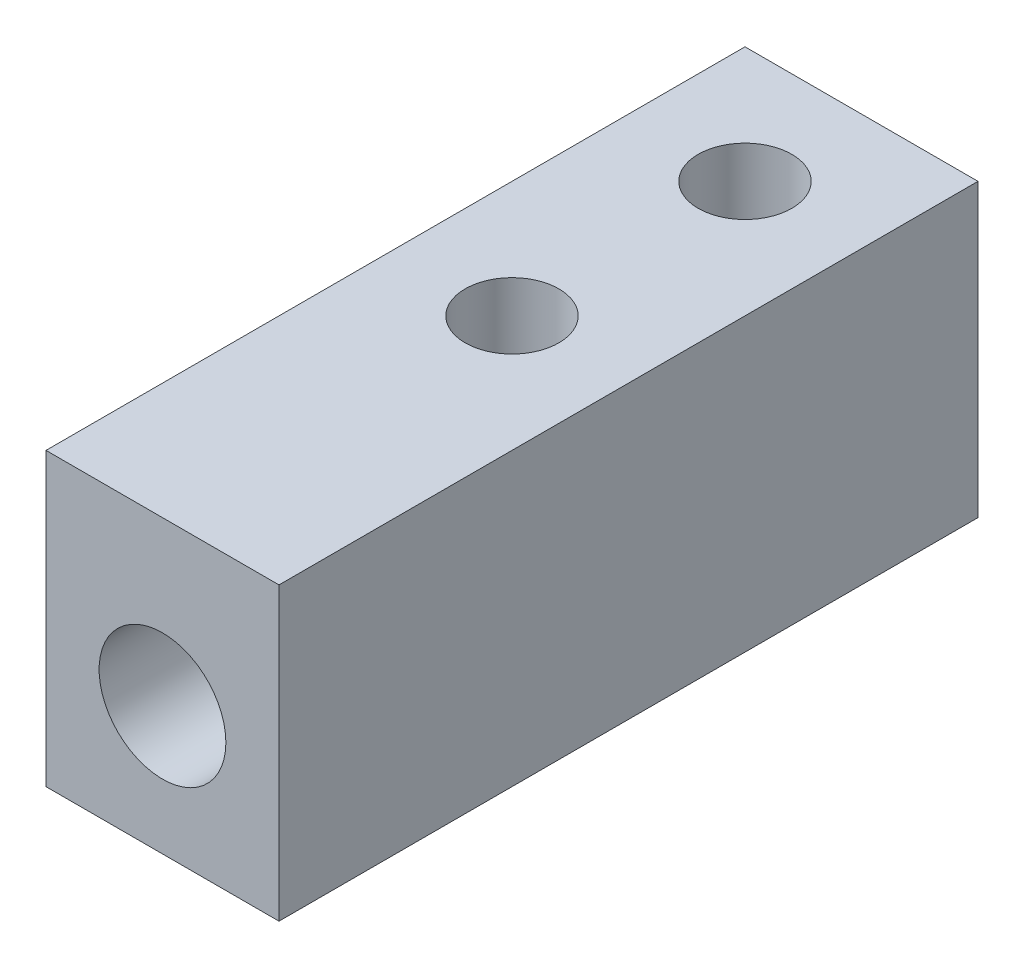
from build123d import *

# Parameters (mm, degrees)
SKETCH1_W                    = 12.7
SKETCH1_H                    = 12.7
BOSS_EXTRUDE1_DEPTH          = 15.875
F_7_0_201_DIAMETER_HOLE1_D   = 5.1054
SKETCH5_W                    = 12.7
SKETCH5_H                    = 12.7
BOSS_EXTRUDE2_DEPTH          = 6.35
F_5_16_24_TAPPED_HOLE1_D     = 6.9088
F_5_16_24_TAPPED_HOLE1_DEPTH = 19.304
F_5_16_24_TAPPED_HOLE1_TIP   = 2.075612922
BOSS_EXTRUDE4_START          = 3.175
SKETCH9_W                    = 12.7
SKETCH9_H                    = 38.1
SKETCH9_R                    = 2.5527
BOSS_EXTRUDE4_DEPTH          = 3.175


with BuildPart() as part:
    # Sketch1 → Boss-Extrude1 (new, symmetric)
    with BuildSketch(Plane.XY):
        Rectangle(SKETCH1_W, SKETCH1_H)
    extrude(amount=BOSS_EXTRUDE1_DEPTH, both=True)

    # #7 (0.201) Diameter Hole1 (through all)
    with Locations(Plane(origin=(0, 6.35, 0), x_dir=(1, 0, 0), z_dir=(0, 1, 0))):
        with Locations((0, -3.175), (0, 9.525)):
            Hole(F_7_0_201_DIAMETER_HOLE1_D / 2)

    # Sketch5 → Boss-Extrude2 (add)
    with BuildSketch(Plane.XY.offset(15.875)):
        Rectangle(SKETCH5_W, SKETCH5_H)
    extrude(amount=BOSS_EXTRUDE2_DEPTH)

    # 5/16-24 Tapped Hole1
    with Locations(Plane.XY.offset(22.225)):
        with Locations((0, -2.54)):
            Hole(F_5_16_24_TAPPED_HOLE1_D / 2, depth=F_5_16_24_TAPPED_HOLE1_DEPTH)
            with Locations((0, 0, -(F_5_16_24_TAPPED_HOLE1_DEPTH + F_5_16_24_TAPPED_HOLE1_TIP / 2))):  # 118° drill point
                Cone(0, F_5_16_24_TAPPED_HOLE1_D / 2, F_5_16_24_TAPPED_HOLE1_TIP, mode=Mode.SUBTRACT)

    # Sketch9 → Boss-Extrude4 (add)
    with BuildSketch(Plane.XZ.offset(6.35).offset(BOSS_EXTRUDE4_START)):
        with Locations((0, 3.175)):
            Rectangle(SKETCH9_W, SKETCH9_H)
        with Locations(Location((0, 3.175, 0), (0, 0, 90))):
            Circle(SKETCH9_R, mode=Mode.SUBTRACT)
        with Locations(Location((0, -9.525, 0), (0, 0, 90))):
            Circle(SKETCH9_R, mode=Mode.SUBTRACT)
    extrude(amount=-BOSS_EXTRUDE4_DEPTH)


solid = part.part
